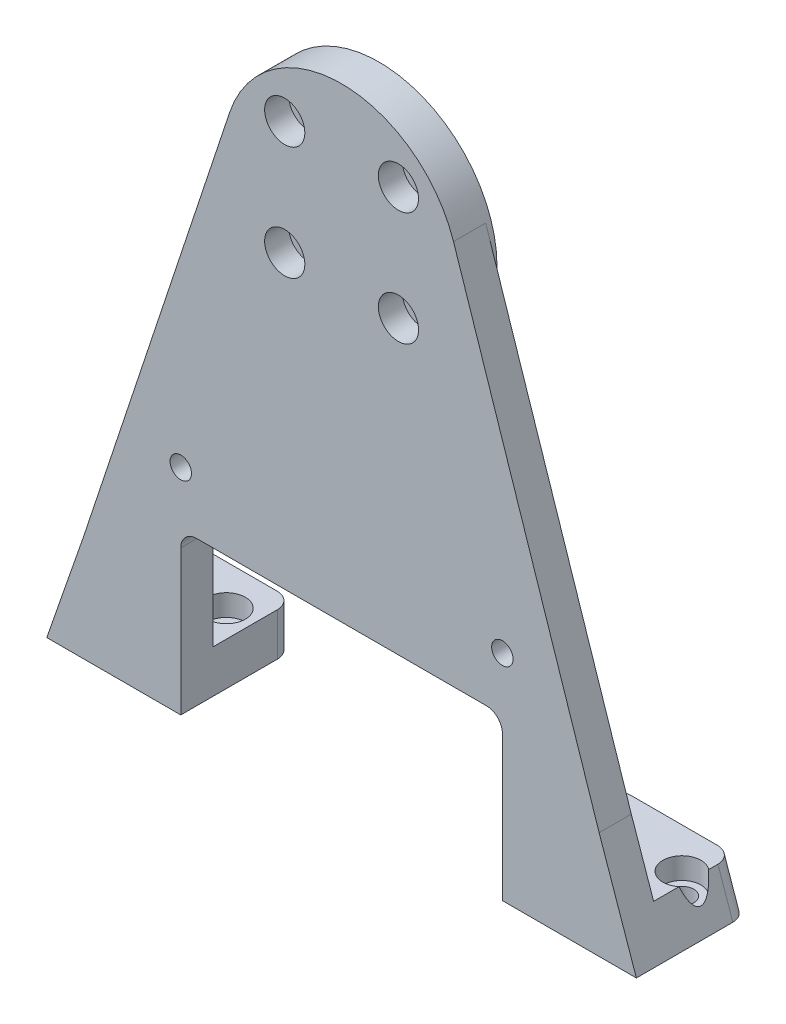
from build123d import *

# Parameters (mm, degrees)
SKETCH1_R           = 22
SKETCH1_R_2         = 2.2
BOSS_EXTRUDE1_DEPTH = 1
SKETCH2_R           = 2
SKETCH2_R_2         = 2.2
BOSS_EXTRUDE2_DEPTH = 6
SKETCH3_W           = 25
SKETCH3_H           = 15
SKETCH3_R           = 2.2
BOSS_EXTRUDE3_DEPTH = 8
CUT_EXTRUDE1_DEPTH  = 16
SKETCH5_R           = 3.55
CUT_EXTRUDE2_DEPTH  = 4
FILLET1_R           = 3
SKETCH6_R           = 3.75
CUT_EXTRUDE3_DEPTH  = 4.5


with BuildPart() as part:
    # Sketch1 → Boss-Extrude1 (new body)
    with BuildSketch(Plane.XY):
        Circle(SKETCH1_R)
        with Locations((10.606601718, 10.606601718)):
            Circle(SKETCH1_R_2, mode=Mode.SUBTRACT)
        with Locations((10.606601718, -10.606601718)):
            Circle(SKETCH1_R_2, mode=Mode.SUBTRACT)
        with Locations((-10.606601718, -10.606601718)):
            Circle(SKETCH1_R_2, mode=Mode.SUBTRACT)
        with Locations((-10.606601718, 10.606601718)):
            Circle(SKETCH1_R_2, mode=Mode.SUBTRACT)
    extrude(amount=BOSS_EXTRUDE1_DEPTH)

    # Sketch2 → Boss-Extrude2 (add)
    with BuildSketch(Plane.XY.offset(1)):
        with BuildLine():
            Line((-48.055, -75), (-55, -95))
            Line((-55, -95), (-30, -95))
            Line((-30, -95), (-30, -65))
            Line((-30, -65), (30, -65))
            Line((30, -65), (30, -95))
            Line((30, -95), (55, -95))
            Line((55, -95), (48.055, -75))
            Line((48.055, -75), (20.881333045, 6.926032793))
            ThreePointArc((20.881333045, 6.926032793), (0, 22), (-20.881333045, 6.926032793))
            Line((-20.881333045, 6.926032793), (-48.055, -75))
        make_face()
        with Locations((-30, -55)):
            Circle(SKETCH2_R, mode=Mode.SUBTRACT)
        with Locations((30, -55)):
            Circle(SKETCH2_R, mode=Mode.SUBTRACT)
        with Locations((-10.606601718, -10.606601718)):
            Circle(SKETCH2_R_2, mode=Mode.SUBTRACT)
        with Locations((-10.606601718, 10.606601718)):
            Circle(SKETCH2_R_2, mode=Mode.SUBTRACT)
        with Locations((10.606601718, -10.606601718)):
            Circle(SKETCH2_R_2, mode=Mode.SUBTRACT)
        with Locations((10.606601718, 10.606601718)):
            Circle(SKETCH2_R_2, mode=Mode.SUBTRACT)
    extrude(amount=BOSS_EXTRUDE2_DEPTH)

    # Sketch3 → Boss-Extrude3 (add)
    with BuildSketch(Plane(origin=(0, -95, 0), x_dir=(-1, 0, 0), z_dir=(0, -1, 0))):
        with Locations((-42.5, 6.5)):
            Rectangle(SKETCH3_W, SKETCH3_H)
        with Locations((-35, 6.5)):
            Circle(SKETCH3_R, mode=Mode.SUBTRACT)
        with Locations((-50, 6.5)):
            Circle(SKETCH3_R, mode=Mode.SUBTRACT)
        with Locations((42.5, 6.5)):
            Rectangle(SKETCH3_W, SKETCH3_H)
        with Locations((50, 6.5)):
            Circle(SKETCH3_R, mode=Mode.SUBTRACT)
        with Locations((35, 6.5)):
            Circle(SKETCH3_R, mode=Mode.SUBTRACT)
    extrude(amount=-BOSS_EXTRUDE3_DEPTH)

    # Sketch4 → Cut-Extrude1 (cut, through all)
    with BuildSketch(Plane.XY.offset(1)):
        Polygon((-55, -95), (-52.222, -87), (-55, -87), align=None)
        Polygon((55, -95), (55, -87), (52.222, -87), align=None)
    extrude(amount=-CUT_EXTRUDE1_DEPTH, mode=Mode.SUBTRACT)

    # Sketch5 → Cut-Extrude2 (cut)
    with BuildSketch(Plane(origin=(0, -87, 0), x_dir=(1, 0, 0), z_dir=(0, 1, 0))):
        with Locations((-50, 6.5)):
            Circle(SKETCH5_R)
        with Locations((-35, 6.5)):
            Circle(SKETCH5_R)
        with Locations((35, 6.5)):
            Circle(SKETCH5_R)
        with Locations((50, 6.5)):
            Circle(SKETCH5_R)
    extrude(amount=-CUT_EXTRUDE2_DEPTH, mode=Mode.SUBTRACT)

    # Fillet1
    fillet1_edges = [part.edges().sort_by_distance(p)[0] for p in [
        (-53.611, -91, -14),
        (53.611, -91, -14),
        (30, -65, 4),
        (-30, -65, 4),
        (30, -91, -14),
        (-30, -91, -14),
    ]]
    fillet(fillet1_edges, radius=FILLET1_R)

    # Sketch6 → Cut-Extrude3 (cut)
    with BuildSketch(Plane.XY.offset(7)):
        with Locations((-10.606601718, 10.606601718)):
            Circle(SKETCH6_R)
        with Locations((10.606601718, 10.606601718)):
            Circle(SKETCH6_R)
        with Locations((10.606601718, -10.606601718)):
            Circle(SKETCH6_R)
        with Locations((-10.606601718, -10.606601718)):
            Circle(SKETCH6_R)
    extrude(amount=-CUT_EXTRUDE3_DEPTH, mode=Mode.SUBTRACT)


solid = part.part
